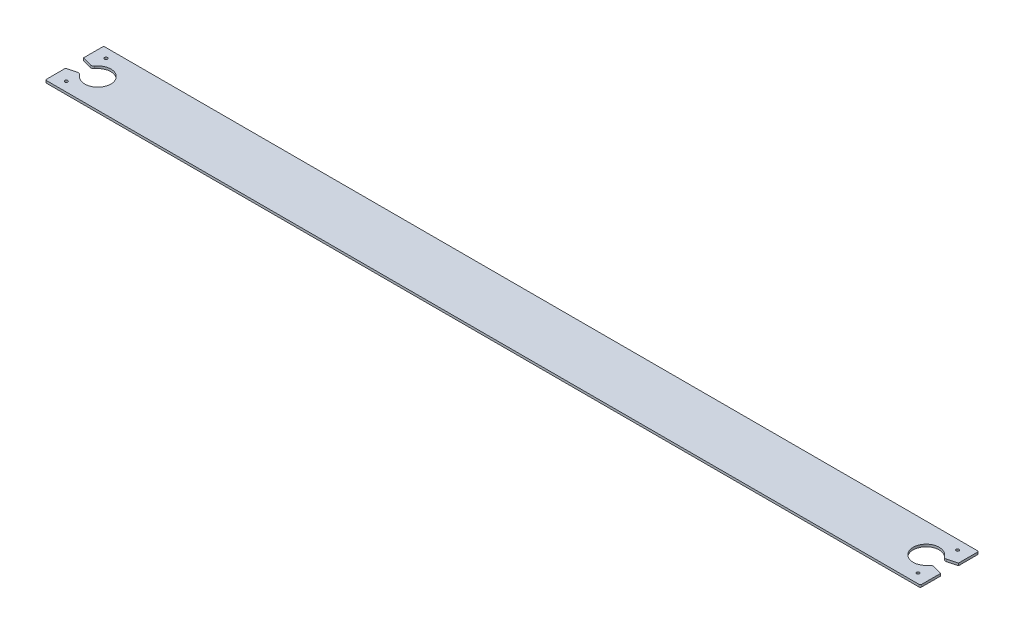
from build123d import *

# Parameters (mm, degrees)
SKETCH1_W           = 750
SKETCH1_H           = 50
SKETCH1_R           = 1.25
BOSS_EXTRUDE1_DEPTH = 2
FILLET1_R           = 1
CUT_EXTRUDE1_DEPTH  = 2


with BuildPart() as part:
    # Sketch1 → Boss-Extrude1 (new body)
    with BuildSketch(Plane(origin=(0, 0, 0), x_dir=(1, 0, 0), z_dir=(0, 1, 0))):
        with Locations((375, 25)):
            Rectangle(SKETCH1_W, SKETCH1_H)
        with Locations((10, 42)):
            Circle(SKETCH1_R, mode=Mode.SUBTRACT)
        with Locations((10, 8)):
            Circle(SKETCH1_R, mode=Mode.SUBTRACT)
        with Locations((740, 8)):
            Circle(SKETCH1_R, mode=Mode.SUBTRACT)
        with Locations((740, 42)):
            Circle(SKETCH1_R, mode=Mode.SUBTRACT)
    extrude(amount=BOSS_EXTRUDE1_DEPTH)

    # Fillet1
    fillet1_edges = [part.edges().sort_by_distance(p)[0] for p in [
        (0, 1, -50),
        (750, 1, -50),
        (750, 1, 0),
        (0, 1, 0),
    ]]
    fillet(fillet1_edges, radius=FILLET1_R)

    # Sketch2 → Cut-Extrude1 (cut)
    with BuildSketch(Plane(origin=(0, 2, 0), x_dir=(1, 0, 0), z_dir=(0, 1, 0))):
        with BuildLine():
            Line((741.815018385, 30.48633271), (750, 32.679491924))
            Line((750, 32.679491924), (750, 17.320508076))
            Line((750, 17.320508076), (741.815018385, 19.51366729))
            ThreePointArc((741.815018385, 19.51366729), (740.31863757, 19.450157279), (739.127091147, 18.542739963))
            ThreePointArc((739.127091147, 18.542739963), (718.819660113, 25), (739.127091147, 31.457260037))
            ThreePointArc((739.127091147, 31.457260037), (740.31863757, 30.549842721), (741.815018385, 30.48633271))
        make_face()
        with BuildLine():
            Line((0, 32.679491924), (0, 17.320508076))
            Line((0, 17.320508076), (8.184981615, 19.51366729))
            ThreePointArc((8.184981615, 19.51366729), (9.68136243, 19.450157279), (10.872908853, 18.542739963))
            ThreePointArc((10.872908853, 18.542739963), (31.180339887, 25), (10.872908853, 31.457260037))
            ThreePointArc((10.872908853, 31.457260037), (9.68136243, 30.549842721), (8.184981615, 30.48633271))
            Line((8.184981615, 30.48633271), (0, 32.679491924))
        make_face()
    extrude(amount=-CUT_EXTRUDE1_DEPTH, mode=Mode.SUBTRACT)


solid = part.part
